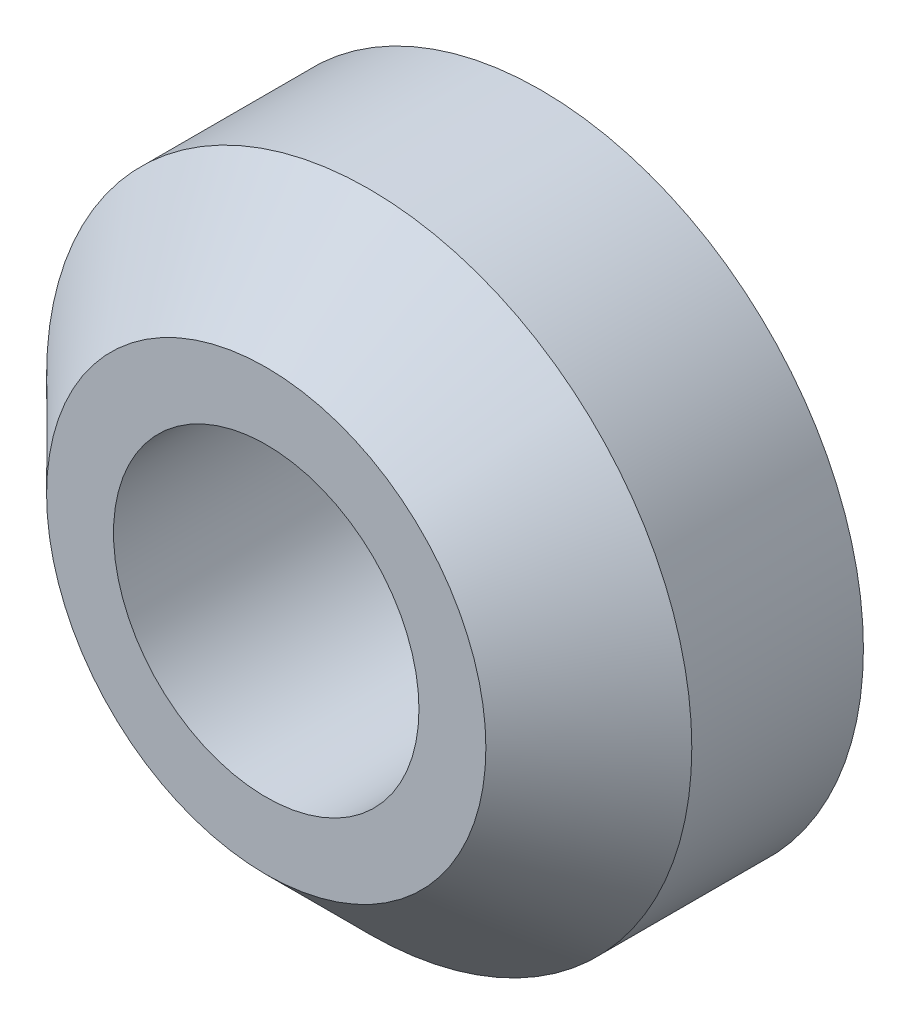
from build123d import *

# Parameters (mm, degrees)
SKETCH1_R      = 2.3876
SKETCH1_R_2    = 1.1303
EXTRUDE1_DEPTH = 2.032
CHAMFER1_SIZE  = 0.762


with BuildPart() as part:
    # Sketch1 → Extrude1 (new body)
    with BuildSketch(Plane.XY):
        Circle(SKETCH1_R)
        Circle(SKETCH1_R_2, mode=Mode.SUBTRACT)
    extrude(amount=EXTRUDE1_DEPTH)

    # Chamfer1
    chamfer1_edges = [part.edges().sort_by_distance(p)[0] for p in [
        (-2.3876, 0, 2.032),
    ]]
    chamfer(chamfer1_edges, length=CHAMFER1_SIZE)


solid = part.part
